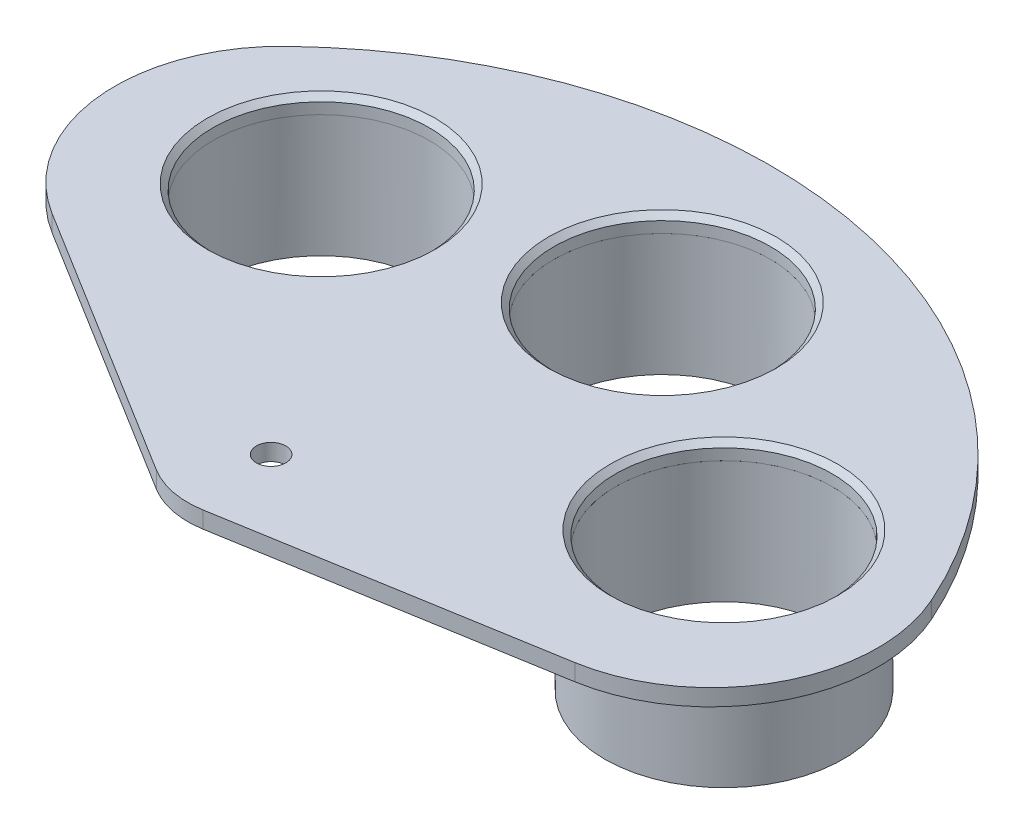
from build123d import *

# Parameters (mm, degrees)
SKETCH1_R           = 19.5
SKETCH1_R_2         = 1
BOSS_EXTRUDE1_DEPTH = 3
SKETCH2_R           = 24
SKETCH2_R_2         = 19.5
BOSS_EXTRUDE2_DEPTH = 3
SKETCH3_R           = 21.5
SKETCH3_R_2         = 19.5
BOSS_EXTRUDE3_DEPTH = 22
CIRPATTERN1_COUNT   = 3
CIRPATTERN1_ANGLE   = 100
CHAMFER1_SIZE       = 1
SKETCH5_W           = 2.65
SKETCH5_H           = 25


with BuildPart() as part:
    # Sketch1 → Boss-Extrude1 (new body)
    with BuildSketch(Plane(origin=(0, 0, 0), x_dir=(1, 0, 0), z_dir=(0, 1, 0))):
        with BuildLine():
            Line((-57.282568216, 17.852377392), (-7.901533034, -12.750128459))
            ThreePointArc((-7.901533034, -12.750128459), (-2.886972844, -14.719558003), (2.5, -14.790199458))
            Line((2.5, -14.790199458), (59.782196187, -5.107741092))
            ThreePointArc((59.782196187, -5.107741092), (81.229417033, 10.311283966), (82.17329428, 36.708986735))
            ThreePointArc((82.17329428, 36.708986735), (17.321837062, 88.317348017), (-62.219253222, 65.028951464))
            ThreePointArc((-62.219253222, 65.028951464), (-71.316587402, 40.230400567), (-57.282568216, 17.852377392))
        make_face()
        with Locations(Location((-37.680500959, 46.692396034, 0), (0, 0, 270))):
            Circle(SKETCH1_R, mode=Mode.SUBTRACT)
        with Locations(Location((11.547891375, 58.878232012, 0), (0, 0, 270))):
            Circle(SKETCH1_R, mode=Mode.SUBTRACT)
        with Locations(Location((52.526183947, 29, 0), (0, 0, 270))):
            Circle(SKETCH1_R, mode=Mode.SUBTRACT)
        with Locations(Location((0, 0, 0), (0, 0, 270))):
            Circle(SKETCH1_R_2, mode=Mode.SUBTRACT)
    extrude(amount=BOSS_EXTRUDE1_DEPTH)

    # Chamfer1
    chamfer1_edges = [part.edges().sort_by_distance(p)[0] for p in [
        (-37.680500959, 3, -66.192396034),
        (11.547891375, 3, -78.378232012),
        (52.526183947, 3, -48.5),
    ]]
    chamfer(chamfer1_edges, length=CHAMFER1_SIZE)

    # Sketch5 → M5 Clearance Hole1 (revolve, cut)
    with BuildSketch(Plane(origin=(0, 3, 0), x_dir=(0, 0, 1), z_dir=(1, 0, 0))):
        with Locations((1.325, 12.5)):
            Rectangle(SKETCH5_W, SKETCH5_H)
    revolve(axis=Axis((0, 9.35, 0), (0, -1, 0)), mode=Mode.SUBTRACT)


with BuildPart() as body_2:
    # Sketch2 → Boss-Extrude2 (new body)
    with BuildSketch(Plane(origin=(0, 0, 0), x_dir=(1, 0, 0), z_dir=(0, 1, 0))):
        with Locations(Location((-37.680500959, 46.692396034, 0), (0, 0, 270))):
            Circle(SKETCH2_R)
        with Locations(Location((-37.680500959, 46.692396034, 0), (0, 0, 270))):
            Circle(SKETCH2_R_2, mode=Mode.SUBTRACT)
    extrude(amount=-BOSS_EXTRUDE2_DEPTH)

    # Sketch3 → Boss-Extrude3 (add)
    with BuildSketch(Plane(origin=(0, 0, 0), x_dir=(-1, 0, 0), z_dir=(0, -1, 0))):
        with Locations(Location((37.680500959, 46.692396034, 0), (0, 0, 270))):
            Circle(SKETCH3_R)
        with Locations(Location((37.680500959, 46.692396034, 0), (0, 0, 270))):
            Circle(SKETCH3_R_2, mode=Mode.SUBTRACT)
    extrude(amount=BOSS_EXTRUDE3_DEPTH)


with BuildPart() as cirpattern1_1:
    # CirPattern1: pattern copy
    add(body_2.part.rotate(Axis((0, 0, 0), (0, -1, 0)), 1 * CIRPATTERN1_ANGLE / (CIRPATTERN1_COUNT - 1)))


with BuildPart() as cirpattern1_2:
    # CirPattern1: pattern copy
    add(body_2.part.rotate(Axis((0, 0, 0), (0, -1, 0)), 2 * CIRPATTERN1_ANGLE / (CIRPATTERN1_COUNT - 1)))


solid = Compound([part.part, body_2.part, cirpattern1_1.part, cirpattern1_2.part])
